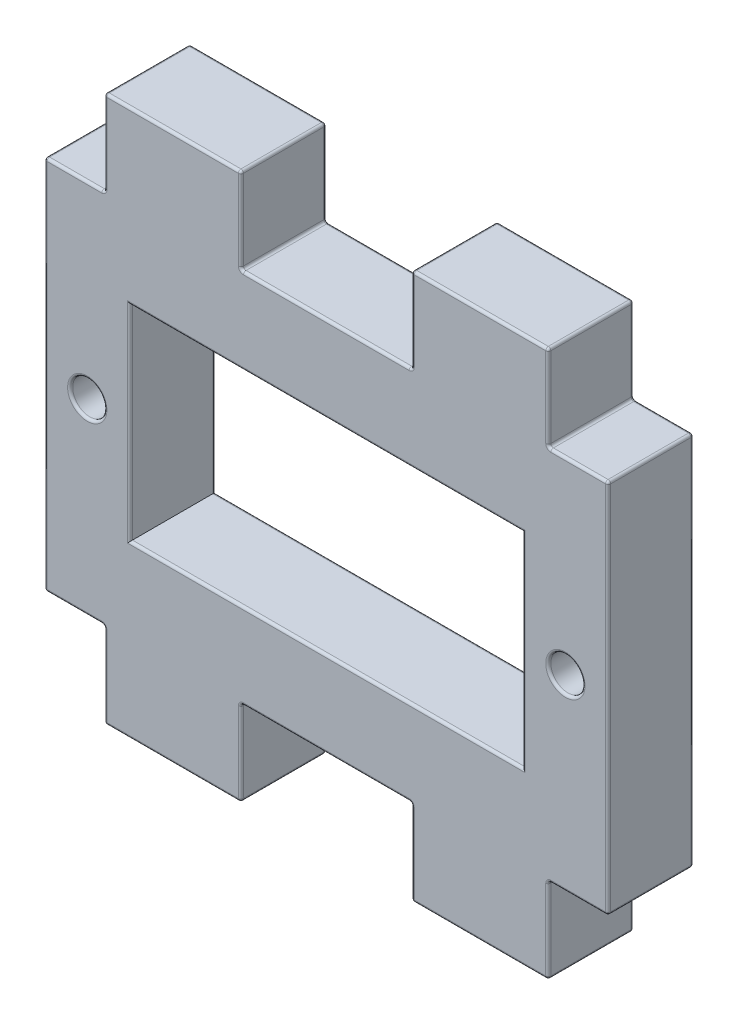
from build123d import *

# Parameters (mm, degrees)
SKETCH1_W           = 8
SKETCH1_H           = 5
SKETCH1_W_2         = 33
SKETCH1_H_2         = 22
SKETCH1_R           = 1
SKETCH1_W_3         = 23
SKETCH1_H_3         = 12
BOSS_EXTRUDE1_DEPTH = 2.5
FILLET2_R           = 0.15
FILLET3_R           = 0.15


with BuildPart() as part:
    # Sketch1 → Boss-Extrude1 (new body, symmetric)
    with BuildSketch(Plane.XY):
        with Locations((-9, -13.5)):
            Rectangle(SKETCH1_W, SKETCH1_H)
        with Locations((9, -13.5)):
            Rectangle(SKETCH1_W, SKETCH1_H)
        Rectangle(SKETCH1_W_2, SKETCH1_H_2)
        with Locations((-14, 0)):
            Circle(SKETCH1_R, mode=Mode.SUBTRACT)
        with Locations((14, 0)):
            Circle(SKETCH1_R, mode=Mode.SUBTRACT)
        Rectangle(SKETCH1_W_3, SKETCH1_H_3, mode=Mode.SUBTRACT)
        with Locations((9, 13.5)):
            Rectangle(SKETCH1_W, SKETCH1_H)
        with Locations((-9, 13.5)):
            Rectangle(SKETCH1_W, SKETCH1_H)
    extrude(amount=BOSS_EXTRUDE1_DEPTH, both=True)

    # Fillet2
    fillet2_edges = [part.edges().sort_by_distance(p)[0] for p in [
        (-9, -16, 2.5),
        (-5, -13.5, 2.5),
        (0, -11, 2.5),
        (-14.75, -11, -2.5),
        (-16.5, 0, -2.5),
        (5, -13.5, 2.5),
        (-14.75, 11, -2.5),
        (5, 13.5, -2.5),
        (9, 16, -2.5),
        (13, 13.5, -2.5),
        (14.75, 11, -2.5),
        (16.5, 0, -2.5),
        (14.75, -11, -2.5),
        (13, -13.5, -2.5),
        (9, -16, -2.5),
        (5, -13.5, -2.5),
        (9, -16, 2.5),
        (0, -11, -2.5),
        (-5, -13.5, -2.5),
        (-9, -16, -2.5),
        (-13, -13.5, -2.5),
        (13, -13.5, 2.5),
        (-13, -11, 0),
        (-16.5, -11, 0),
        (-16.5, 11, 0),
        (5, 11, 0),
        (5, 16, 0),
        (13, 16, 0),
        (13, 11, 0),
        (16.5, 11, 0),
        (16.5, -11, 0),
        (13, -11, 0),
        (13, -16, 0),
        (5, -16, 0),
        (5, -11, 0),
        (14.75, -11, 2.5),
        (-5, -11, 0),
        (-5, -16, 0),
        (-13, -16, 0),
        (16.5, 0, 2.5),
        (14.75, 11, 2.5),
        (13, 13.5, 2.5),
        (0, 11, -2.5),
        (9, 16, 2.5),
        (0, 11, 2.5),
        (-5, 11, 0),
        (-13, 11, 0),
        (5, 13.5, 2.5),
        (-5, 16, 0),
        (-13, 16, 0),
        (-9, 16, 2.5),
        (-5, 13.5, 2.5),
        (-13, 13.5, 2.5),
        (-9, 16, -2.5),
        (-14.75, 11, 2.5),
        (-5, 13.5, -2.5),
        (-13, 13.5, -2.5),
        (-16.5, 0, 2.5),
        (-13, -13.5, 2.5),
        (-14.75, -11, 2.5),
    ]]
    fillet(fillet2_edges, radius=FILLET2_R)

    # Fillet3
    fillet3_edges = [part.edges().sort_by_distance(p)[0] for p in [
        (-15, 0, 2.5),
        (13, 0, 2.5),
        (13, 0, -2.5),
        (-15, 0, -2.5),
        (0, 6, -2.5),
        (-11.5, 0, -2.5),
        (0, -6, -2.5),
        (11.5, 0, -2.5),
        (11.5, 0, 2.5),
        (0, -6, 2.5),
        (-11.5, 0, 2.5),
        (0, 6, 2.5),
    ]]
    fillet(fillet3_edges, radius=FILLET3_R)


solid = part.part
